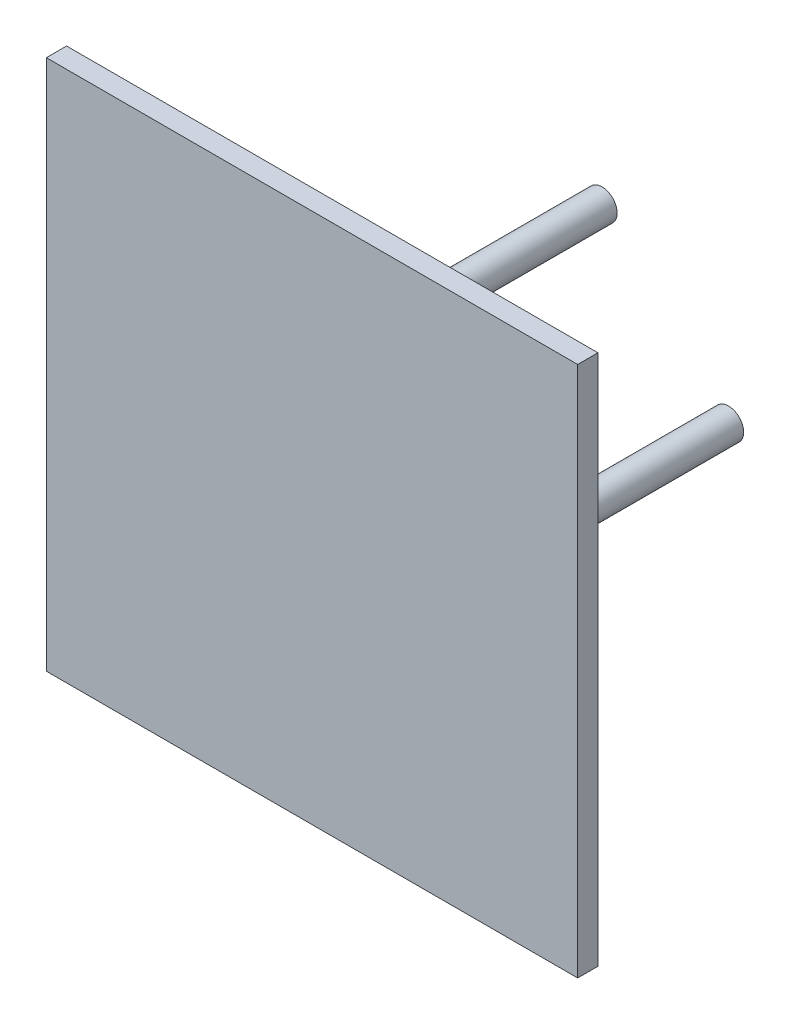
from build123d import *

# Parameters (mm, degrees)
SKETCH1_W           = 105
SKETCH1_H           = 105
BOSS_EXTRUDE1_DEPTH = 4
SKETCH2_R           = 3
CUT_EXTRUDE1_DEPTH  = 2
BOSS_EXTRUDE5_DEPTH = 12
SKETCH4_R           = 1.998701955
CUT_EXTRUDE2_DEPTH  = 12
FILLET1_R           = 1
SKETCH5_R           = 3
BOSS_EXTRUDE7_DEPTH = 53.3


with BuildPart() as part:
    # Sketch1 → Boss-Extrude1 (new body)
    with BuildSketch(Plane.XY):
        with Locations((52.5, 52.5)):
            Rectangle(SKETCH1_W, SKETCH1_H)
    extrude(amount=BOSS_EXTRUDE1_DEPTH)

    # Sketch2 → Cut-Extrude1 (cut)
    with BuildSketch(Plane(origin=(0, 0, 0), x_dir=(-1, 0, 0), z_dir=(0, 0, -1))):
        with Locations((-52.5, 52.5)):
            Circle(SKETCH2_R)
    extrude(amount=-CUT_EXTRUDE1_DEPTH, mode=Mode.SUBTRACT)

    # Sketch3 → Boss-Extrude5 (add)
    with BuildSketch(Plane(origin=(0, 0, 0), x_dir=(-1, 0, 0), z_dir=(0, 0, -1))):
        with BuildLine():
            Line((-46.5, 55), (-40, 55))
            Line((-40, 55), (-40, 53))
            Line((-40, 53), (-49.440588292, 53))
            ThreePointArc((-49.440588292, 53), (-55.6, 52.5), (-49.440588292, 52))
            Line((-49.440588292, 52), (-40, 52))
            Line((-40, 52), (-40, 50))
            Line((-40, 50), (-46.5, 50))
            ThreePointArc((-46.5, 50), (-59, 52.5), (-46.5, 55))
        make_face()
    extrude(amount=BOSS_EXTRUDE5_DEPTH)

    # Sketch4 → Cut-Extrude2 (cut)
    with BuildSketch(Plane(origin=(0, 55, 0), x_dir=(1, 0, 0), z_dir=(0, 1, 0))):
        with Locations((43.25, 6)):
            Circle(SKETCH4_R)
    extrude(amount=-CUT_EXTRUDE2_DEPTH, mode=Mode.SUBTRACT)

    # Fillet1
    fillet1_edges = [part.edges().sort_by_distance(p)[0] for p in [
        (40, 54, -12),
        (40, 51, -12),
    ]]
    fillet(fillet1_edges, radius=FILLET1_R)

    # Sketch5 → Boss-Extrude7 (add)
    with BuildSketch(Plane(origin=(0, 0, 0), x_dir=(-1, 0, 0), z_dir=(0, 0, -1))):
        with Locations((-52.5, 77.5)):
            Circle(SKETCH5_R)
        with Locations((-27.5, 52.5)):
            Circle(SKETCH5_R)
        with Locations((-52.5, 27.5)):
            Circle(SKETCH5_R)
        with Locations((-77.5, 52.5)):
            Circle(SKETCH5_R)
    extrude(amount=BOSS_EXTRUDE7_DEPTH)


solid = part.part
